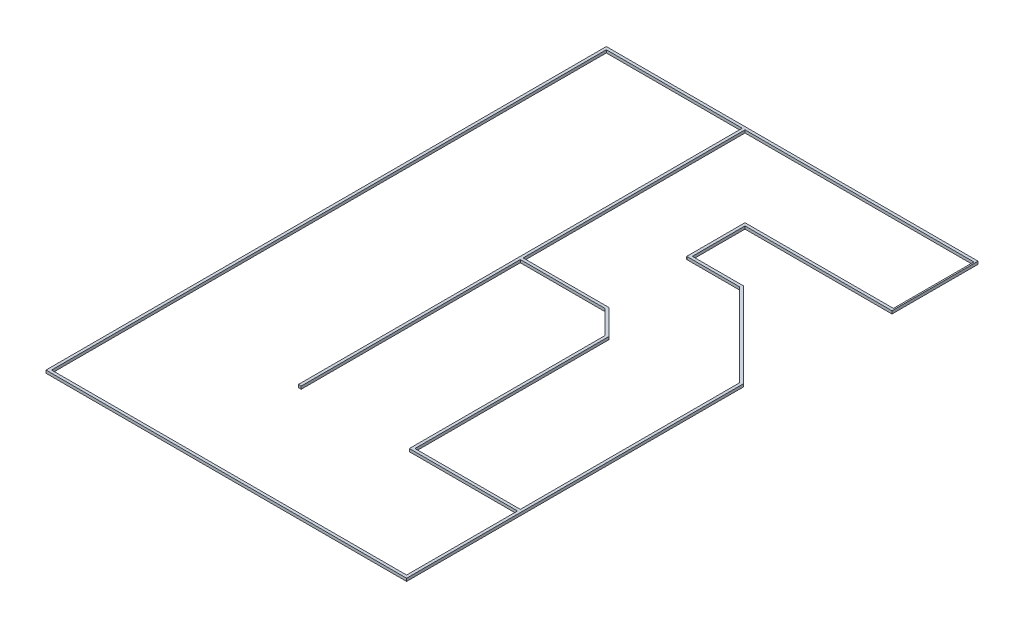
from build123d import *

# Parameters (mm, degrees)
SKETCH1_W           = 1900
SKETCH1_H           = 50
BOSS_EXTRUDE1_DEPTH = 50.8


with BuildPart() as part:
    # Sketch1 → Boss-Extrude1 (new body)
    with BuildSketch(Plane(origin=(0, 0, 0), x_dir=(1, 0, 0), z_dir=(0, 1, 0))):
        Polygon((0, 6720.514582342), (0, 6670.514582342), (-2625, 6670.514582342), (-2625, 5720.514582342), (-1704.289321881, 5720.514582342), (-175, 4191.225260461), (-175, -1879.485417658), (-6675, -1879.485417658), (-6675, 8220.514582342), (0, 8220.514582342), (0, 8170.514582342), (-6625, 8170.514582342), (-6625, -1829.485417658), (-225, -1829.485417658), (-225, 4170.514582342), (-1725, 5670.514582342), (-2675, 5670.514582342), (-2675, 6720.514582342), align=None)
        Polygon((0, 8170.514582342), (0, 6720.514582342), (0, 6670.514582342), (25, 6670.514582342), (25, 8220.514582342), (0, 8220.514582342), align=None)
        Polygon((-4125, 4120.514582342), (-4125, 4170.514582342), (-4125, 8170.514582342), (-4175, 8170.514582342), (-4175, 170.514582342), (-4125, 170.514582342), align=None)
        Polygon((-2125, 170.514582342), (-2125, 220.514582342), (-2125, 3720.514582342), (-2575, 4170.514582342), (-4125, 4170.514582342), (-4125, 4120.514582342), (-2595.710678119, 4120.514582342), (-2175, 3699.803904224), (-2175, 170.514582342), align=None)
        with Locations((-1175, 195.514582342)):
            Rectangle(SKETCH1_W, SKETCH1_H)
    extrude(amount=BOSS_EXTRUDE1_DEPTH)


solid = part.part
